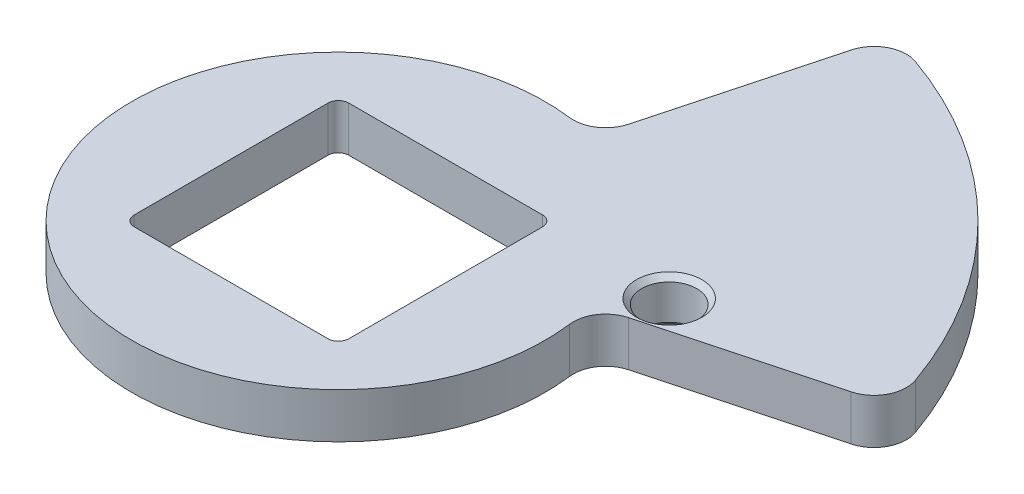
from build123d import *

# Parameters (mm, degrees)
SKETCH2_R           = 2.706768225
SKETCH2_W           = 21.082
SKETCH2_H           = 21.082
BOSS_EXTRUDE1_DEPTH = 4.445
FILLET1_R           = 3.175
FILLET2_R           = 1.016
CHAMFER1_SIZE       = 0.508


with BuildPart() as part:
    # Sketch2 → Boss-Extrude1 (new body)
    with BuildSketch(Plane(origin=(0, 0, 0), x_dir=(1, 0, 0), z_dir=(0, 1, 0))):
        with BuildLine():
            Line((11.504506555, 42.935402979), (5.259202996, 19.62761279))
            ThreePointArc((5.259202996, 19.62761279), (-14.368409794, -14.368409794), (19.62761279, 5.259202996))
            Line((19.62761279, 5.259202996), (42.935402979, 11.504506555))
            ThreePointArc((42.935402979, 11.504506555), (31.430896424, 31.430896424), (11.504506555, 42.935402979))
        make_face()
        with Locations((22.86, 9.652)):
            Circle(SKETCH2_R, mode=Mode.SUBTRACT)
        Rectangle(SKETCH2_W, SKETCH2_H, mode=Mode.SUBTRACT)
    extrude(amount=BOSS_EXTRUDE1_DEPTH)

    # Fillet1
    fillet1_edges = [part.edges().sort_by_distance(p)[0] for p in [
        (42.935402979, 2.2225, -11.504506555),
        (19.62761279, 2.2225, -5.259202996),
        (5.259202996, 2.2225, -19.62761279),
        (11.504506555, 2.2225, -42.935402979),
    ]]
    fillet(fillet1_edges, radius=FILLET1_R)

    # Fillet2
    fillet2_edges = [part.edges().sort_by_distance(p)[0] for p in [
        (10.541, 2.2225, 10.541),
        (10.541, 2.2225, -10.541),
        (-10.541, 2.2225, -10.541),
        (-10.541, 2.2225, 10.541),
    ]]
    fillet(fillet2_edges, radius=FILLET2_R)

    # Chamfer1
    chamfer1_edges = [part.edges().sort_by_distance(p)[0] for p in [
        (20.153231775, 0, -9.652),
        (20.153231775, 4.445, -9.652),
    ]]
    chamfer(chamfer1_edges, length=CHAMFER1_SIZE)


solid = part.part
